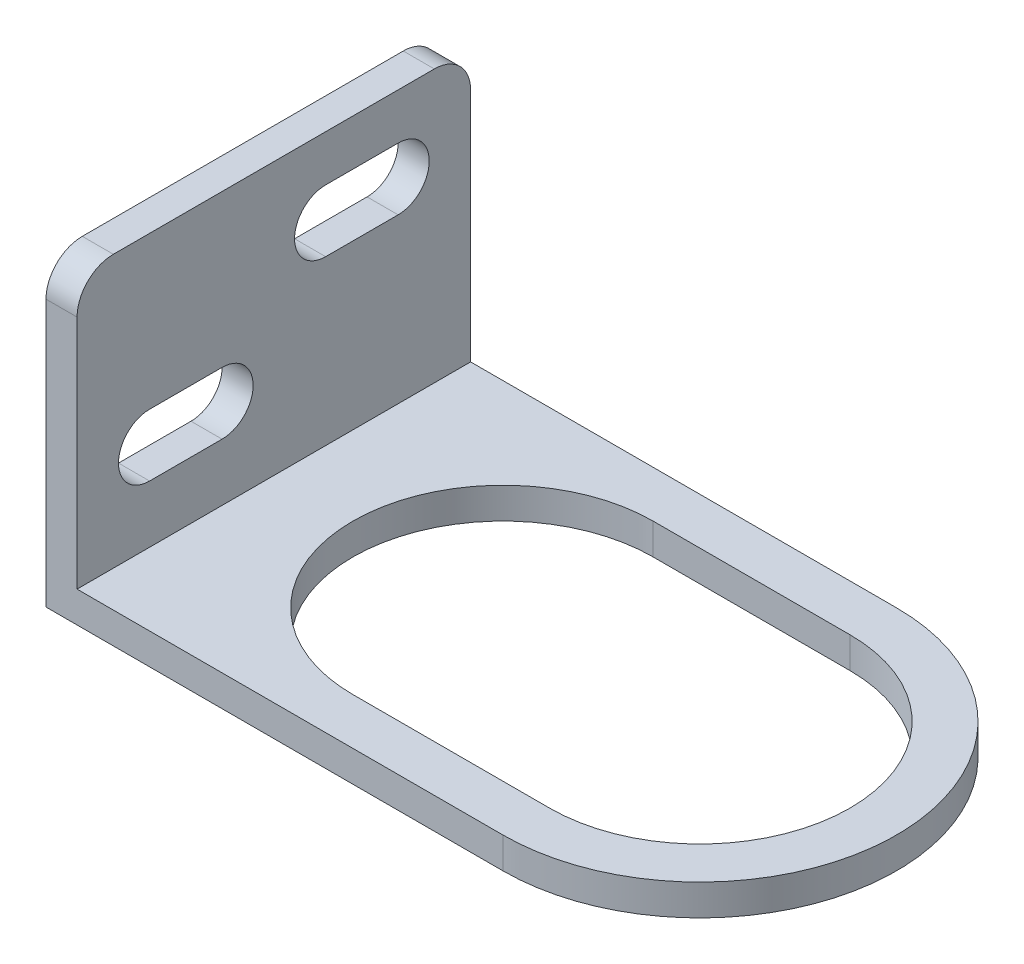
from build123d import *

# Parameters (mm, degrees)
EXTRUDE_THIN1_DEPTH = 19
CUT_EXTRUDE1_DEPTH  = 4
CUT_EXTRUDE2_DEPTH  = 10


with BuildPart() as part:
    # Sketch2 → Extrude-Thin1 (new body, symmetric)
    with BuildSketch(Plane.XY):
        Polygon((-1.5, 32), (-1.5, -1.5), (63, -1.5), (63, 1.5), (1.5, 1.5), (1.5, 32), align=None)
    extrude(amount=EXTRUDE_THIN1_DEPTH, both=True)

    # Sketch3 → Cut-Extrude1 (cut, through all)
    with BuildSketch(Plane(origin=(1.5, 0, 0), x_dir=(0, 0, -1), z_dir=(1, 0, 0))):
        with BuildLine():
            Line((5, 23.298608028), (12, 23.298608028))
            ThreePointArc((12, 23.298608028), (15, 20.298608028), (12, 17.298608028))
            Line((12, 17.298608028), (5, 17.298608028))
            ThreePointArc((5, 17.298608028), (2, 20.298608028), (5, 23.298608028))
        make_face()
        with BuildLine():
            Line((-12, 13.03992903), (-5, 13.03992903))
            ThreePointArc((-5, 13.03992903), (-2, 10.03992903), (-5, 7.03992903))
            Line((-5, 7.03992903), (-12, 7.03992903))
            ThreePointArc((-12, 7.03992903), (-15, 10.03992903), (-12, 13.03992903))
        make_face()
        with BuildLine():
            Line((-15.496537692, 27.749610789), (15.496537692, 27.749610789))
            ThreePointArc((15.496537692, 27.749610789), (17.973859648, 26.723470437), (19, 24.246148481))
            Line((19, 24.246148481), (19, 32))
            Line((19, 32), (-19, 32))
            Line((-19, 32), (-19, 24.246148481))
            ThreePointArc((-19, 24.246148481), (-17.973859648, 26.723470437), (-15.496537692, 27.749610789))
        make_face()
    extrude(amount=-CUT_EXTRUDE1_DEPTH, mode=Mode.SUBTRACT)

    # Sketch4 → Cut-Extrude2 (cut)
    with BuildSketch(Plane(origin=(0, 1.5, 0), x_dir=(1, 0, 0), z_dir=(0, 1, 0))):
        with BuildLine():
            Line((42.625671961, -14.5), (23.625671961, -14.5))
            ThreePointArc((23.625671961, -14.5), (9.125671961, 0), (23.625671961, 14.5))
            Line((23.625671961, 14.5), (42.625671961, 14.5))
            ThreePointArc((42.625671961, 14.5), (57.125671961, 0), (42.625671961, -14.5))
        make_face()
        with BuildLine():
            Line((42.625671961, 19), (63, 19))
            Line((63, 19), (63, -19))
            Line((63, -19), (42.625671961, -19))
            ThreePointArc((42.625671961, -19), (61.625671961, 0), (42.625671961, 19))
        make_face()
    extrude(amount=-CUT_EXTRUDE2_DEPTH, mode=Mode.SUBTRACT)


solid = part.part
